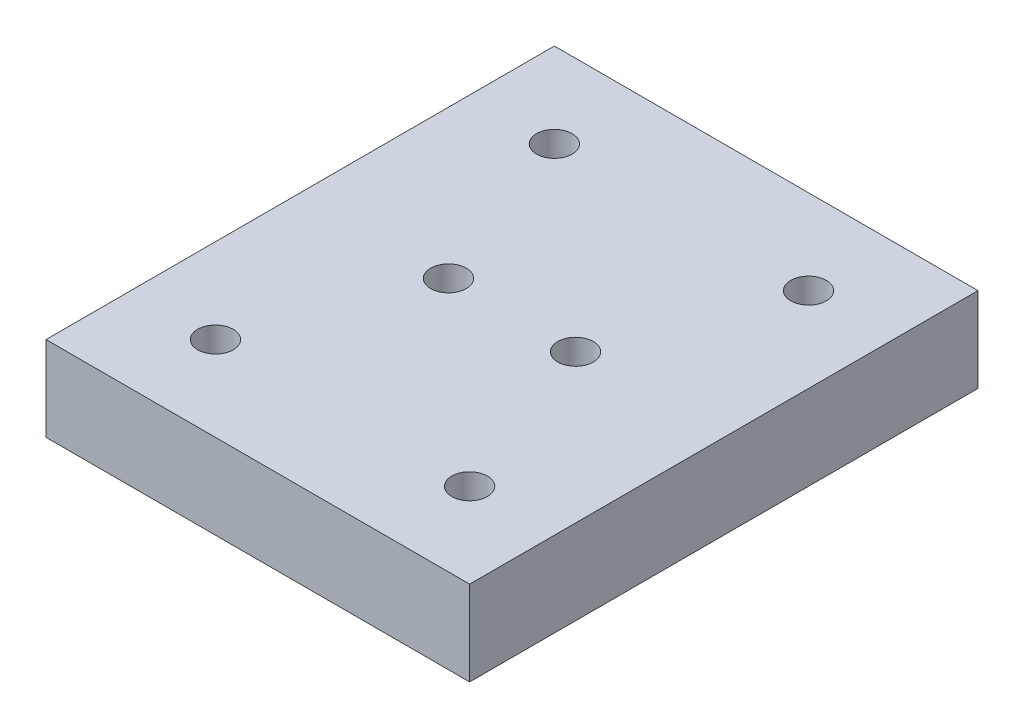
from build123d import *

# Parameters (mm, degrees)
SKETCH1_W           = 50
SKETCH1_H           = 60
BOSS_EXTRUDE1_DEPTH = 10
M5_TAPPED_HOLE1_D   = 4.2
M5_TAPPED_HOLE2_D   = 4.2


with BuildPart() as part:
    # Sketch1 → Boss-Extrude1 (new body)
    with BuildSketch(Plane(origin=(0, 0, 0), x_dir=(1, 0, 0), z_dir=(0, 1, 0))):
        Rectangle(SKETCH1_W, SKETCH1_H)
    extrude(amount=BOSS_EXTRUDE1_DEPTH)

    # M5 Tapped Hole1 (through all)
    with Locations(Plane(origin=(0, 10, 0), x_dir=(1, 0, 0), z_dir=(0, 1, 0))):
        with Locations((-7.5, 0), (7.5, 0)):
            Hole(M5_TAPPED_HOLE1_D / 2)

    # M5 Tapped Hole2 (through all)
    with Locations(Plane(origin=(0, 10, 0), x_dir=(1, 0, 0), z_dir=(0, 1, 0))):
        with Locations((15, 20), (-15, 20), (-15, -20), (15, -20)):
            Hole(M5_TAPPED_HOLE2_D / 2)


solid = part.part
